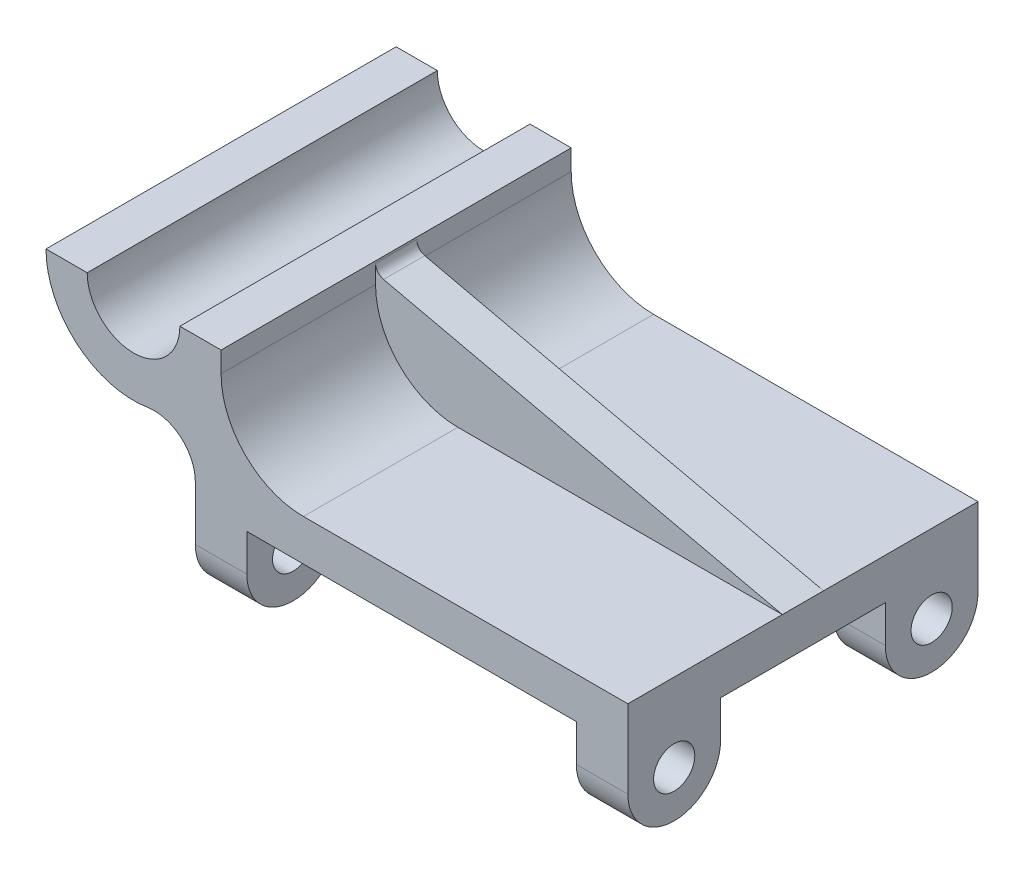
from build123d import *

# Parameters (mm, degrees)
BOSS_EXTRUDE1_DEPTH = 53.975
SKETCH3_R           = 6.35
BOSS_EXTRUDE2_DEPTH = 133.35
SKETCH4_W           = 101.6
SKETCH4_H           = 25.718784162
CUT_EXTRUDE1_DEPTH  = 168.885161643
RIB3_REACH          = 141.447
SKETCH5_WALL_W      = 411.489550618
SKETCH5_WALL_H      = 12.7
FILLET1_R           = 3.175


with BuildPart() as part:
    # Sketch1 → Boss-Extrude1 (new, symmetric)
    with BuildSketch(Plane.XY):
        with BuildLine():
            Line((120.65, 0), (-12.7, 0))
            Line((-12.7, 0), (-12.7, 5.273793493))
            ThreePointArc((-12.7, 5.273793493), (-17.169459313, 14.945825338), (-27.432, 17.810179575))
            ThreePointArc((-27.432, 17.810179575), (-49.23989896, 23.896932331), (-58.7375, 44.45))
            Line((-58.7375, 44.45), (-46.0375, 44.45))
            ThreePointArc((-46.0375, 44.45), (-31.75, 30.1625), (-17.4625, 44.45))
            Line((-17.4625, 44.45), (-4.7625, 44.45))
            Line((-4.7625, 44.45), (-4.7625, 38.1))
            ThreePointArc((-4.7625, 38.1), (2.676987758, 20.139487758), (20.6375, 12.7))
            Line((20.6375, 12.7), (120.65, 12.7))
            Line((120.65, 12.7), (120.65, 0))
        make_face()
    extrude(amount=BOSS_EXTRUDE1_DEPTH, both=True)

    # Sketch3 → Boss-Extrude2 (add)
    with BuildSketch(Plane(origin=(120.65, 0, 0), x_dir=(0, 0, -1), z_dir=(1, 0, 0))):
        with BuildLine():
            Line((-53.975, -11.431284162), (-53.975, 0))
            Line((-53.975, 0), (-25.4, 0))
            Line((-25.4, 0), (-25.4, -11.431284162))
            ThreePointArc((-25.4, -11.431284162), (-39.6875, -25.718784162), (-53.975, -11.431284162))
        make_face()
        with Locations((-39.6875, -11.431284162)):
            Circle(SKETCH3_R, mode=Mode.SUBTRACT)
        with BuildLine():
            Line((53.975, 0), (25.4, 0))
            Line((25.4, 0), (25.4, -11.431284162))
            ThreePointArc((25.4, -11.431284162), (39.6875, -25.718784162), (53.975, -11.431284162))
            Line((53.975, -11.431284162), (53.975, 0))
        make_face()
        with Locations((39.6875, -11.431284162)):
            Circle(SKETCH3_R, mode=Mode.SUBTRACT)
    extrude(amount=-BOSS_EXTRUDE2_DEPTH)

    # Sketch4 → Cut-Extrude1 (cut, through all)
    with BuildSketch(Plane.XY.offset(53.975)):
        with Locations((53.975, -12.859392081)):
            Rectangle(SKETCH4_W, SKETCH4_H)
    extrude(amount=-CUT_EXTRUDE1_DEPTH, mode=Mode.SUBTRACT)

    # Sketch5 wall → Rib3 (add, up to next)
    with BuildSketch(Plane(origin=(56.984129031, 27.206147816, 0), x_dir=(-0.975011472973, 0.222154512832, 0), z_dir=(-0.222154512832, -0.975011472973, 0)), mode=Mode.PRIVATE) as rib3_sk1:
        Rectangle(SKETCH5_WALL_W, SKETCH5_WALL_H)
    rib3_tool1 = extrude(rib3_sk1.sketch, amount=RIB3_REACH, mode=Mode.PRIVATE) - part.part
    add(rib3_tool1.solids().sort_by_distance((56.984129031, 27.206147816, 0))[0])

    # Fillet1
    fillet1_edges = [part.edges().sort_by_distance(p)[0] for p in [
        (-4.7625, 41.275, 0),
    ]]
    fillet(fillet1_edges, radius=FILLET1_R)


solid = part.part
